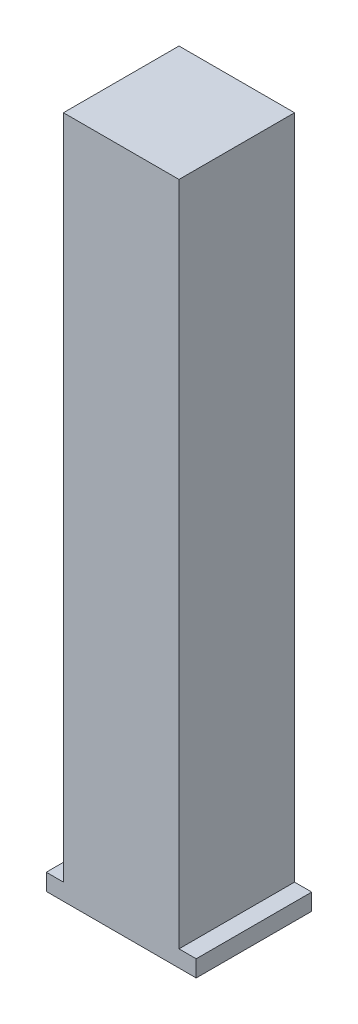
from build123d import *

# Parameters (mm, degrees)
SKETCH1_W           = 28.575
SKETCH1_H           = 22.024999892
BOSS_EXTRUDE1_DEPTH = 3.175
SKETCH2_W           = 22.024999892
SKETCH2_H           = 22.024999892
BOSS_EXTRUDE2_DEPTH = 127


with BuildPart() as part:
    # Sketch1 → Boss-Extrude1 (new body)
    with BuildSketch(Plane(origin=(0, 0, 0), x_dir=(1, 0, 0), z_dir=(0, 1, 0))):
        Rectangle(SKETCH1_W, SKETCH1_H)
    extrude(amount=BOSS_EXTRUDE1_DEPTH)

    # Sketch2 → Boss-Extrude2 (add)
    with BuildSketch(Plane(origin=(0, 3.175, 0), x_dir=(1, 0, 0), z_dir=(0, 1, 0))):
        Rectangle(SKETCH2_W, SKETCH2_H)
    extrude(amount=BOSS_EXTRUDE2_DEPTH)


solid = part.part
